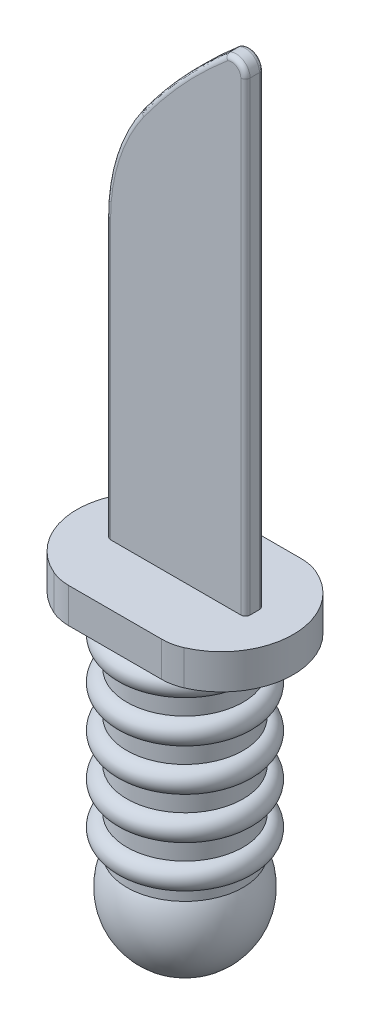
from build123d import *

# Parameters (mm, degrees)
SKETCH1_R                = 1.25
BOSS_EXTRUDE1_DEPTH      = 4.5
BOSS_EXTRUDE2_DEPTH      = 0.75
DOME1_FACE_RADIUS        = 1.25
DOME1_HEIGHT             = 2
BOSS_EXTRUDE3_DEPTH      = 0.2
BOSS_EXTRUDE3_DEPTH_BACK = 0.2
FILLET3_R                = 0.1
SKETCH5_R                = 0.25
LPATTERN1_COUNT          = 5
LPATTERN1_PITCH          = 0.9


with BuildPart() as part:
    # Sketch1 → Boss-Extrude1 (new body)
    with BuildSketch(Plane(origin=(0, 0, 0), x_dir=(1, 0, 0), z_dir=(0, 1, 0))):
        Circle(SKETCH1_R)
    extrude(amount=BOSS_EXTRUDE1_DEPTH)

    # Sketch2 → Boss-Extrude2 (add)
    with BuildSketch(Plane(origin=(0, 4.5, 0), x_dir=(1, 0, 0), z_dir=(0, 1, 0))):
        with BuildLine():
            Line((1, 1.5), (-1, 1.5))
            ThreePointArc((-1, 1.5), (-1.204309644, 1.478906313), (-1.4, 1.416515139))
            ThreePointArc((-1.4, 1.416515139), (-2.327326835, 0), (-1.4, -1.416515139))
            ThreePointArc((-1.4, -1.416515139), (-1.204309644, -1.478906313), (-1, -1.5))
            Line((-1, -1.5), (0.012678076, -1.5))
            Line((0.012678076, -1.5), (1, -1.5))
            ThreePointArc((1, -1.5), (1.204309644, -1.478906313), (1.4, -1.416515139))
            ThreePointArc((1.4, -1.416515139), (2.327326835, 0), (1.4, 1.416515139))
            ThreePointArc((1.4, 1.416515139), (1.204309644, 1.478906313), (1, 1.5))
        make_face()
    extrude(amount=BOSS_EXTRUDE2_DEPTH)

    # Dome1: a dome of height H over a round flat face of radius A is a cap of a sphere of radius (A * A + H * H) / (2 * H)
    dome1_r = (DOME1_FACE_RADIUS * DOME1_FACE_RADIUS + DOME1_HEIGHT * DOME1_HEIGHT) / (2 * DOME1_HEIGHT)
    dome1_base = Plane((0, 0, 0), z_dir=(0, -1, 0))
    with Locations(dome1_base.offset(DOME1_HEIGHT - dome1_r)):
        dome1_ball = Sphere(dome1_r, mode=Mode.PRIVATE)
    add(split(dome1_ball, bisect_by=dome1_base, keep=Keep.TOP, mode=Mode.PRIVATE))

    # Sketch3 → Boss-Extrude3 (add, two sides)
    with BuildSketch(Plane.XY) as boss_extrude3_sk:
        with BuildLine():
            Line((1.5, 5.25), (1.5, 15.25))
            ThreePointArc((1.5, 15.25), (1.357181775, 15.505526691), (1.064707402, 15.517760925))
            add(Edge.make_bspline(
                [(-0.764810822, 13.5430934), (0.031541874, 14.643656101), (1.064707402, 15.517760925)],
                knots=[0, 0, 0, 1, 1, 1], degree=2))
            ThreePointArc((-0.764810822, 13.5430934), (-1.311774081, 12.444622397), (-1.5, 11.23203081))
            Line((-1.5, 11.23203081), (-1.5, 5.25))
            Line((-1.5, 5.25), (1.5, 5.25))
        make_face()
    extrude(amount=BOSS_EXTRUDE3_DEPTH)
    extrude(boss_extrude3_sk.sketch, amount=-BOSS_EXTRUDE3_DEPTH_BACK)

    # Fillet3
    fillet3_edges = [part.edges().sort_by_distance(p)[0] for p in [
        (-1.5, 8.241015405, -0.2),
        (-1.311774081, 12.444622397, -0.2),
        (0.089869414, 14.58609638, -0.2),
        (1.357181775, 15.505526691, -0.2),
        (1.5, 10.25, -0.2),
        (1.5, 10.25, 0.2),
        (1.357181775, 15.505526691, 0.2),
        (0.089869414, 14.58609638, 0.2),
        (-1.311774081, 12.444622397, 0.2),
        (-1.5, 8.241015405, 0.2),
    ]]
    fillet(fillet3_edges, radius=FILLET3_R)

    # Sweep1: sweep along a path in Sketch4
    with BuildLine(Plane(origin=(0, 0.5, 0), x_dir=(1, 0, 0), z_dir=(0, 1, 0))) as sweep1_path:
        CenterArc((0, 0), 1.25, 0, 360)
    # Sketch5 → Sweep1 (sweep)
    with BuildSketch(Plane.XY):
        with Locations((-1.25, 0.5)):
            Circle(SKETCH5_R)
    sweep1 = sweep(path=sweep1_path.line)

    # LPattern1: Sweep1 ×5
    with Locations(*[(0, i * LPATTERN1_PITCH, 0) for i in range(1, LPATTERN1_COUNT)]):
        add(sweep1)


solid = part.part
